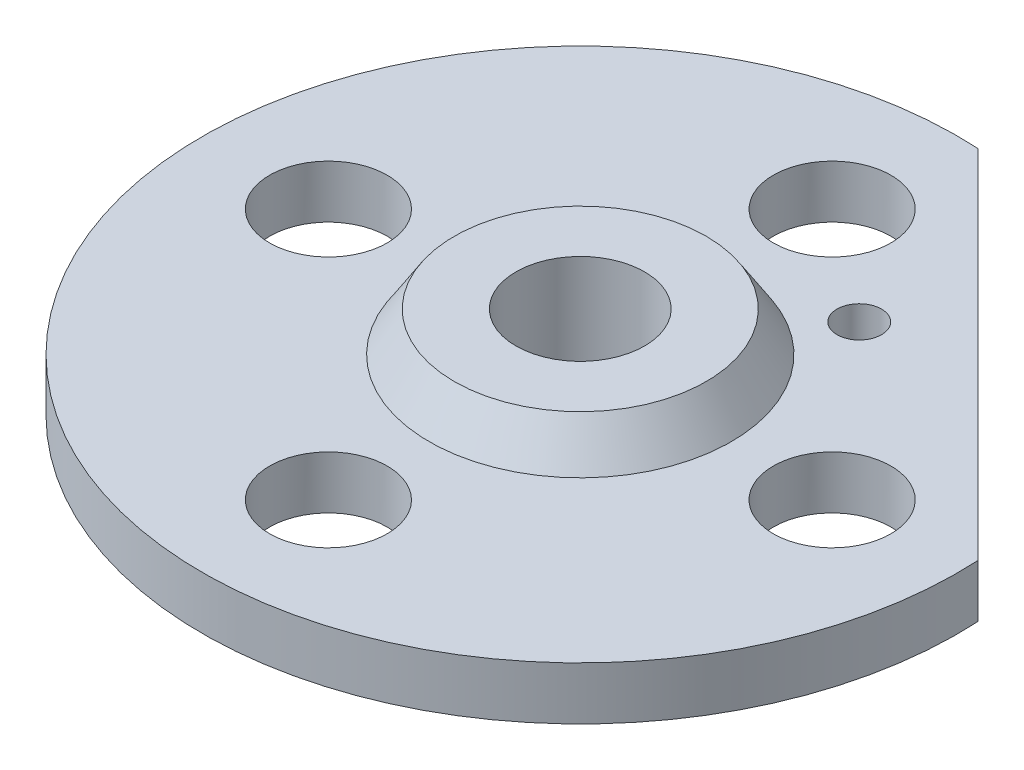
from build123d import *

# Parameters (mm, degrees)
F_14_0_14_DURCHMESSER_BOHRUNG2_D = 14
KREISMUSTER2_COUNT               = 4
F_3_8_18_NPSM_GEWINDEBOHRUNG1_D  = 15.3162
SCHNITT_LINEAR_AUSTRAGEN1_DEPTH  = 6.3
F_5_3_5_3_DURCHMESSER_BOHRUNG1_D = 5.3


with BuildPart() as part:
    # Skizze1 → Rotation1 (revolve)
    with BuildSketch(Plane.XY):
        Polygon((15, 12), (0, 12), (0, 0), (20, 0), (21, 1), (45, 1), (45, 7.3), (18, 7.3), align=None)
    revolve(axis=Axis((0, 0, 0), (0, 1, 0)))

    # Ø14.0 (14) Durchmesser Bohrung2 (through all)
    with Locations(Plane(origin=(0, 7.3, 0), x_dir=(1, 0, 0), z_dir=(0, 1, 0))):
        with Locations((0, 30)):
            f_14_0_14_durchmesser_bohrung2 = Hole(F_14_0_14_DURCHMESSER_BOHRUNG2_D / 2)

    # Kreismuster2: Ø14.0 (14) Durchmesser Bohrung2 ×4 about axis
    kreismuster2_axis = Axis((0, 0, 0), (0, 1, 0))
    for i in range(1, KREISMUSTER2_COUNT):
        add(f_14_0_14_durchmesser_bohrung2.rotate(kreismuster2_axis, i * 360 / KREISMUSTER2_COUNT), mode=Mode.SUBTRACT)

    # 3/8-18 NPSM Gewindebohrung1 (through all)
    with Locations(Plane(origin=(0, 12, 0), x_dir=(1, 0, 0), z_dir=(0, 1, 0))):
        with Locations((0, 0)):
            Hole(F_3_8_18_NPSM_GEWINDEBOHRUNG1_D / 2)

    # Skizze16 → Schnitt-Linear austragen1 (cut)
    with BuildSketch(Plane(origin=(0, 7.3, 0), x_dir=(1, 0, 0), z_dir=(0, 1, 0))):
        with BuildLine():
            Line((44.933664947, 2.442489393), (2.442489393, 44.933664947))
            ThreePointArc((2.442489393, 44.933664947), (31.819805153, 31.819805153), (44.933664947, 2.442489393))
        make_face()
    extrude(amount=-SCHNITT_LINEAR_AUSTRAGEN1_DEPTH, mode=Mode.SUBTRACT)

    # Ø5.3 (5.3) Durchmesser Bohrung1 (through all)
    with Locations(Plane(origin=(0, 7.3, 0), x_dir=(1, 0, 0), z_dir=(0, 1, 0))):
        with Locations((13.25528115, 19.978737566)):
            Hole(F_5_3_5_3_DURCHMESSER_BOHRUNG1_D / 2)


solid = part.part
